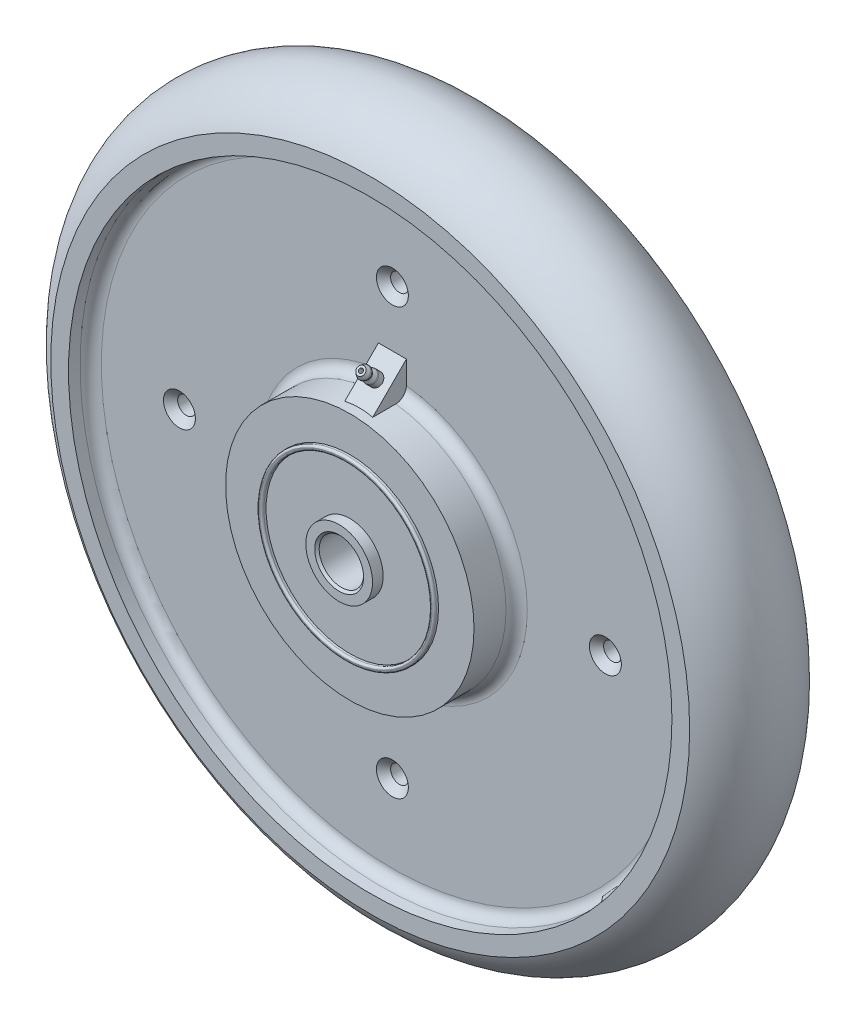
from build123d import *

# Parameters (mm, degrees)
BOSS_EXTRUDE1_DEPTH = 5
SKETCH7_R           = 3.175
CUT_EXTRUDE1_DEPTH  = 60.69
CHAMFER1_SIZE       = 2.54


with BuildPart() as part:
    # Sketch3 → Revolve1 (revolve)
    with BuildSketch(Plane(origin=(0, 0, 0), x_dir=(0, 0, -1), z_dir=(1, 0, 0))):
        with BuildLine():
            Line((-20.6375, 114.3), (-20.6375, 107.95))
            Line((-20.6375, 107.95), (-16.51, 107.95))
            ThreePointArc((-16.51, 107.95), (-13.815923164, 106.834076836), (-12.7, 104.14))
            Line((-12.7, 104.14), (-12.7, 48.26))
            ThreePointArc((-12.7, 48.26), (-13.815923164, 45.565923164), (-16.51, 44.45))
            Line((-16.51, 44.45), (-27.94, 44.45))
            Line((-27.94, 44.45), (-27.94, 31.75))
            Line((-27.94, 31.75), (27.94, 31.75))
            Line((27.94, 31.75), (27.94, 44.45))
            Line((27.94, 44.45), (12.7, 44.45))
            Line((12.7, 44.45), (12.7, 107.95))
            Line((12.7, 107.95), (20.6375, 107.95))
            Line((20.6375, 107.95), (20.6375, 114.3))
            ThreePointArc((20.6375, 114.3), (0, 127), (-20.6375, 114.3))
        make_face()
    revolve(axis=Axis((0, 0, 31.75), (0, 0, -1)))

    # Sketch5 → Boss-Extrude1 (add, symmetric)
    with BuildSketch(Plane(origin=(0, 0, 0), x_dir=(0, 0, -1), z_dir=(1, 0, 0))):
        Polygon((-25.320625, 43.576875), (-11.826875, 57.070625), (-11.826875, 43.576875), align=None)
    extrude(amount=BOSS_EXTRUDE1_DEPTH, both=True)

    # Sketch7 → Cut-Extrude1 (cut, through all)
    with BuildSketch(Plane(origin=(0, 0, -27.94), x_dir=(-1, 0, 0), z_dir=(0, 0, -1))):
        with Locations((0, 76.2)):
            Circle(SKETCH7_R)
        with Locations((76.2, 0)):
            Circle(SKETCH7_R)
        with Locations((0, -76.2)):
            Circle(SKETCH7_R)
        with Locations((-76.2, 0)):
            Circle(SKETCH7_R)
    extrude(amount=-CUT_EXTRUDE1_DEPTH, mode=Mode.SUBTRACT)

    # Chamfer1
    chamfer1_edges = [part.edges().sort_by_distance(p)[0] for p in [
        (3.175, 76.2, -12.7),
        (3.175, 76.2, 12.7),
        (-73.025, 0, -12.7),
        (-73.025, 0, 12.7),
        (3.175, -76.2, -12.7),
        (3.175, -76.2, 12.7),
        (79.375, 0, -12.7),
        (79.375, 0, 12.7),
    ]]
    chamfer(chamfer1_edges, length=CHAMFER1_SIZE)


with BuildPart() as body_2:
    # Sketch4 → Revolve2 (revolve)
    with BuildSketch(Plane(origin=(0, 0, 0), x_dir=(0, 0, -1), z_dir=(1, 0, 0))):
        with BuildLine():
            Line((31.75, 7.9375), (31.75, 11.9375))
            Line((31.75, 11.9375), (29.464, 11.9375))
            Line((29.464, 11.9375), (29.464, 31.75))
            Line((29.464, 31.75), (-28.702, 31.75))
            ThreePointArc((-28.702, 31.75), (-29.240815367, 31.526815367), (-29.464, 30.988))
            Line((-29.464, 30.988), (-29.464, 30.734))
            ThreePointArc((-29.464, 30.734), (-29.240815367, 30.195184633), (-28.702, 29.972))
            Line((-28.702, 29.972), (-27.94, 29.972))
            Line((-27.94, 29.972), (-27.94, 11.9375))
            Line((-27.94, 11.9375), (-31.75, 11.9375))
            Line((-31.75, 11.9375), (-31.75, 8.7375))
            Line((-31.75, 8.7375), (-30.95, 7.9375))
            Line((-30.95, 7.9375), (31.75, 7.9375))
        make_face()
    revolve(axis=Axis((0, 0, 31.75), (0, 0, -1)))


with BuildPart() as body_3:
    # Sketch6 → Revolve3 (revolve)
    with BuildSketch(Plane(origin=(0, 0, 0), x_dir=(0, 0, -1), z_dir=(1, 0, 0))):
        with BuildLine():
            Line((-23.431573587, 56.242233759), (-22.892758219, 56.781049126))
            Line((-22.892758219, 56.781049126), (-21.607841197, 56.329591794))
            ThreePointArc((-21.607841197, 56.329591794), (-21.273914318, 56.119473658), (-21.063796182, 55.785546779))
            Line((-21.063796182, 55.785546779), (-20.621531238, 54.526792707))
            Line((-20.621531238, 54.526792707), (-19.151055668, 54.010139129))
            ThreePointArc((-19.151055668, 54.010139129), (-18.972288932, 53.923838261), (-18.817128789, 53.800020993))
            Line((-18.817128789, 53.800020993), (-16.957303898, 51.940196102))
            Line((-16.957303898, 51.940196102), (-18.043419914, 50.854080086))
            Line((-18.043419914, 50.854080086), (-23.431573587, 56.242233759))
        make_face()
    revolve(axis=Axis((0, 50.32375, 18.57375), (0, 0.707106781, 0.707106781)))


solid = Compound([part.part, body_2.part, body_3.part])
